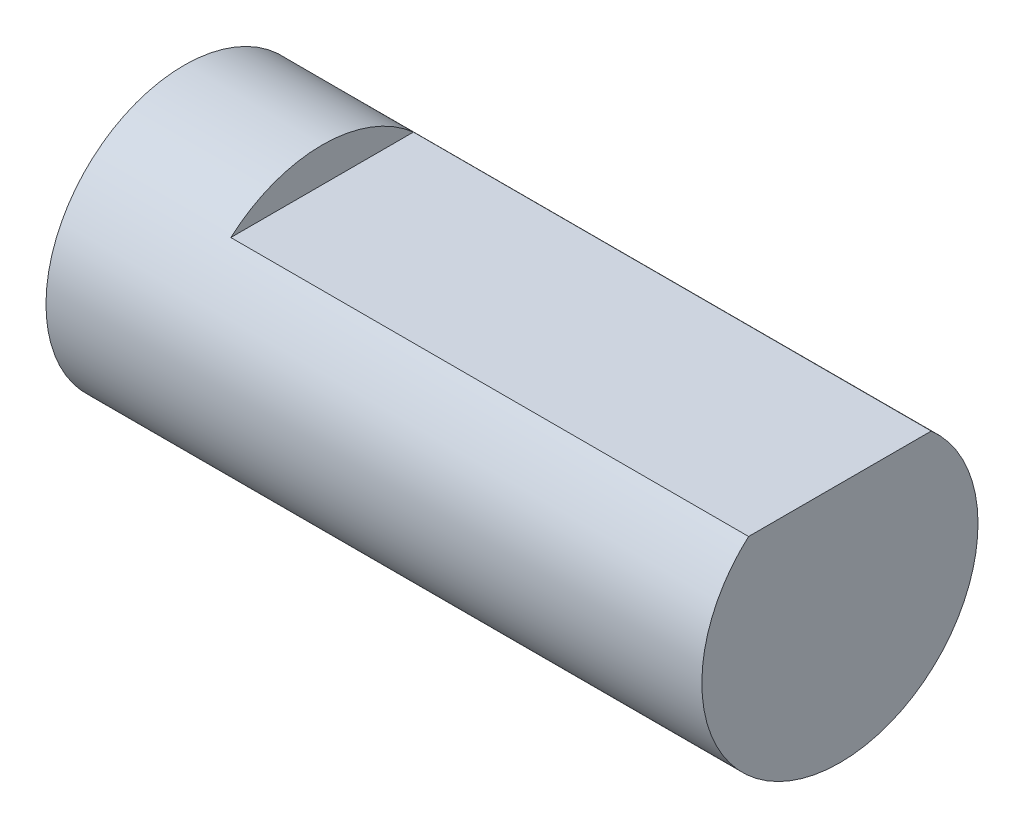
from build123d import *

# Parameters (mm, degrees)
SCHIZZO1_R                   = 4
ESTRUSIONE_ESTRUSIONE1_DEPTH = 19
TAGLIO_ESTRUSIONE1_DEPTH     = 15


with BuildPart() as part:
    # Schizzo1 → Estrusione-Estrusione1 (new body)
    with BuildSketch(Plane(origin=(0, 0, 0), x_dir=(0, 0, -1), z_dir=(1, 0, 0))):
        Circle(SCHIZZO1_R)
    extrude(amount=ESTRUSIONE_ESTRUSIONE1_DEPTH)

    # Schizzo2 → Taglio-Estrusione1 (cut)
    with BuildSketch(Plane(origin=(19, 0, 0), x_dir=(0, 0, -1), z_dir=(1, 0, 0))):
        Polygon((-31.950259643, 3), (-2.645751311, 3), (2.645751311, 3), (31.950259643, 3), (31.950259643, 61.609016665), (-31.950259643, 61.609016665), align=None)
    extrude(amount=-TAGLIO_ESTRUSIONE1_DEPTH, mode=Mode.SUBTRACT)


solid = part.part
